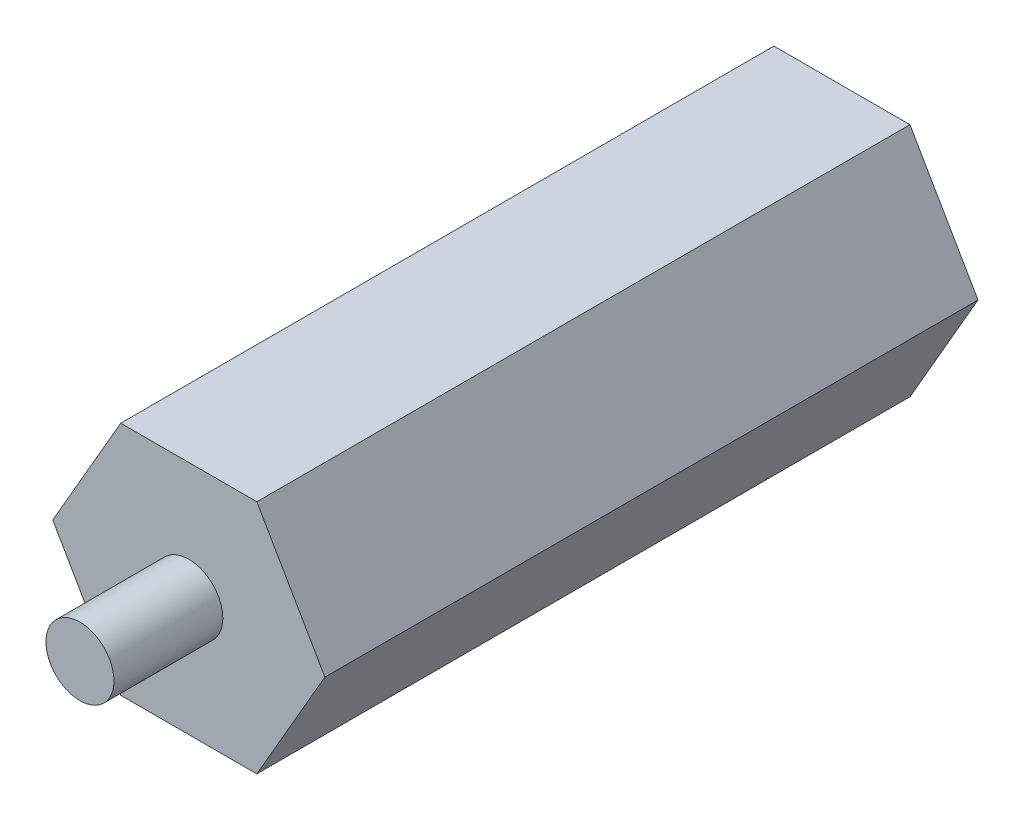
from build123d import *

# Parameters (mm, degrees)
SALIENTE_EXTRUIR1_DEPTH = 304.8
CROQUIS4_R              = 15.875
SALIENTE_EXTRUIR2_DEPTH = 50.8
CROQUIS5_R              = 15.875
SALIENTE_EXTRUIR3_DEPTH = 25.4


with BuildPart() as part:
    # Croquis2 → Saliente-Extruir1 (new body)
    with BuildSketch(Plane.XY):
        Polygon((-63.5, 0), (-31.75, -54.99261314), (31.75, -54.99261314), (63.5, 0), (31.75, 54.99261314), (-31.75, 54.99261314), align=None)
    extrude(amount=-SALIENTE_EXTRUIR1_DEPTH)

    # Croquis4 → Saliente-Extruir2 (add)
    with BuildSketch(Plane.XY):
        Circle(CROQUIS4_R)
    extrude(amount=SALIENTE_EXTRUIR2_DEPTH)

    # Croquis5 → Saliente-Extruir3 (add)
    with BuildSketch(Plane(origin=(0, 0, -304.8), x_dir=(-1, 0, 0), z_dir=(0, 0, -1))):
        Circle(CROQUIS5_R)
    extrude(amount=SALIENTE_EXTRUIR3_DEPTH)


solid = part.part
